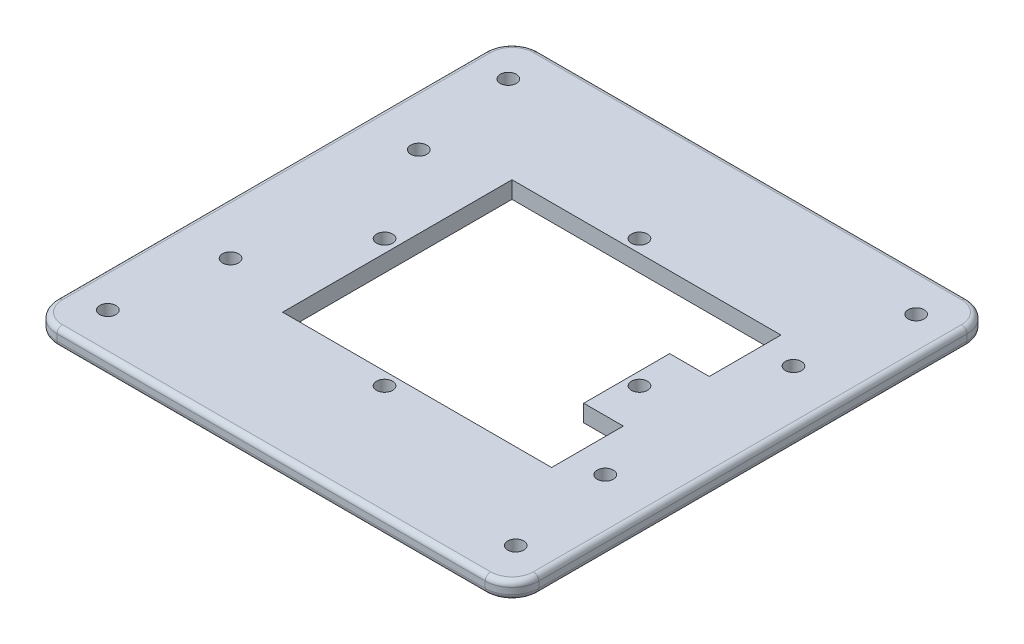
from build123d import *

# Parameters (mm, degrees)
ALUMINUM_PLATE_DEPTH         = 3.175
SKETCH5_W                    = 7.394678559
SKETCH5_H                    = 13.40037918
SKETCH5_H_2                  = 13.400379181
CUT_EXTRUDE18_DEPTH          = 3.175
LPATTERN1_COUNT              = 2
LPATTERN1_PITCH              = 70
LPATTERN1_COUNT_DIR2         = 2
LPATTERN1_PITCH_DIR2         = 35.16147
CIRPATTERN1_COUNT            = 4
F_3_0_3_DIAMETER_HOLE5_D     = 3
F_3_0_3_DIAMETER_HOLE5_DEPTH = 25.4
F_3_0_3_DIAMETER_HOLE5_TIP   = 0.901290929
FILLET1_R                    = 1


with BuildPart() as part:
    # Sketch2 → Aluminum plate (new body)
    with BuildSketch(Plane(origin=(0, 0, 0), x_dir=(1, 0, 0), z_dir=(0, 1, 0))):
        with BuildLine():
            Line((58.411953225, -27.670918752), (-21.588046771, -27.670918749))
            ThreePointArc((-21.588046771, -27.670918749), (-25.123580677, -26.206452654), (-26.588046771, -22.670918748))
            Line((-26.588046771, -22.670918748), (-26.588046767, 57.329032922))
            ThreePointArc((-26.588046767, 57.329032922), (-25.123563586, 60.864583915), (-21.587998438, 62.329032922))
            Line((-21.587998438, 62.329032922), (58.412001558, 62.328259655))
            ThreePointArc((58.412001558, 62.328259655), (61.947504222, 60.863776475), (63.411953229, 57.328259655))
            Line((63.411953229, 57.328259655), (63.411953225, -22.670918752))
            ThreePointArc((63.411953225, -22.670918752), (61.947487131, -26.206452658), (58.411953225, -27.670918752))
        make_face()
        Polygon((39.839453224, -4.0986466), (-3.015546772, -4.098646598), (-3.01554677, 38.756353402), (39.83945323, 38.7563534), align=None, mode=Mode.SUBTRACT)
    extrude(amount=ALUMINUM_PLATE_DEPTH)

    # Sketch5 → Cut-Extrude18 (cut)
    with BuildSketch(Plane(origin=(0, 3.175, 0), x_dir=(1, 0, 0), z_dir=(0, 1, 0))):
        with Locations((43.53679251, 2.60154299)):
            Rectangle(SKETCH5_W, SKETCH5_H)
        with Locations((43.53679251, 32.056163809)):
            Rectangle(SKETCH5_W, SKETCH5_H_2)
    extrude(amount=-CUT_EXTRUDE18_DEPTH, mode=Mode.SUBTRACT)

    # Sketch12 → Ø3.0 (3) Diameter Hole3 (revolve, cut)
    with BuildSketch(Plane(origin=(-16.588046767, 3.175, -34.909587365), x_dir=(0, 0, 1), z_dir=(1, 0, 0))):
        Polygon((0, 0), (0, 26.301290929), (1.5, 25.4), (1.5, 0), align=None)
    f_3_0_3_diameter_hole3 = revolve(axis=Axis((-16.588046767, 9.525, -34.909587365), (0, -1, 0)), mode=Mode.SUBTRACT)

    # LPattern1: 3.0 _3_ Diameter Hole3 2 × 2
    with Locations(*[(i * LPATTERN1_PITCH, 0, j * LPATTERN1_PITCH_DIR2) for i in range(LPATTERN1_COUNT) for j in range(LPATTERN1_COUNT_DIR2) if (i, j) != (0, 0)]):
        add(f_3_0_3_diameter_hole3, mode=Mode.SUBTRACT)

    # Sketch14 → Ø3.0 (3) Diameter Hole4 (revolve, cut)
    with BuildSketch(Plane(origin=(42.221953226, 3.175, -17.329161252), x_dir=(0, 0, 1), z_dir=(1, 0, 0))):
        Polygon((0, 0), (0, 26.301290929), (1.5, 25.4), (1.5, 0), align=None)
    f_3_0_3_diameter_hole4 = revolve(axis=Axis((42.221953226, 9.525, -17.329161252), (0, -1, 0)), mode=Mode.SUBTRACT)

    # CirPattern1: Ø3.0 (3) Diameter Hole4 ×4 about axis
    cirpattern1_axis = Axis((18.411953227, 48.172334768, -17.328853403), (0, -1, 0))
    for i in range(1, CIRPATTERN1_COUNT):
        add(f_3_0_3_diameter_hole4.rotate(cirpattern1_axis, i * 360 / CIRPATTERN1_COUNT), mode=Mode.SUBTRACT)

    # Ø3.0 (3) Diameter Hole5
    with Locations(Plane.XZ):
        with Locations((-19.688046767, -54.730581251), (56.511953233, -54.730581251), (56.511953233, 20.072418749), (-19.688046767, 20.072418749)):
            Hole(F_3_0_3_DIAMETER_HOLE5_D / 2, depth=F_3_0_3_DIAMETER_HOLE5_DEPTH)
            with Locations((0, 0, -(F_3_0_3_DIAMETER_HOLE5_DEPTH + F_3_0_3_DIAMETER_HOLE5_TIP / 2))):  # 118° drill point
                Cone(0, F_3_0_3_DIAMETER_HOLE5_D / 2, F_3_0_3_DIAMETER_HOLE5_TIP, mode=Mode.SUBTRACT)

    # Fillet1
    fillet1_edges = [part.edges().sort_by_distance(p)[0] for p in [
        (-25.123580677, 0, 26.206452654),
        (-26.588046769, 0, -17.329057087),
        (-25.123563586, 0, -60.864583915),
        (18.41200156, 0, -62.328646289),
        (61.947504222, 0, -60.863776475),
        (63.411953227, 0, -17.328670452),
        (61.947487131, 0, 26.206452658),
        (61.947504222, 3.175, -60.863776475),
        (63.411953227, 3.175, -17.328670452),
        (61.947487131, 3.175, 26.206452658),
        (18.411953227, 3.175, 27.67091875),
        (-25.123580677, 3.175, 26.206452654),
        (-26.588046769, 3.175, -17.329057087),
        (-25.123563586, 3.175, -60.864583915),
        (18.411953227, 0, 27.67091875),
        (18.41200156, 3.175, -62.328646289),
    ]]
    fillet(fillet1_edges, radius=FILLET1_R)


solid = part.part
